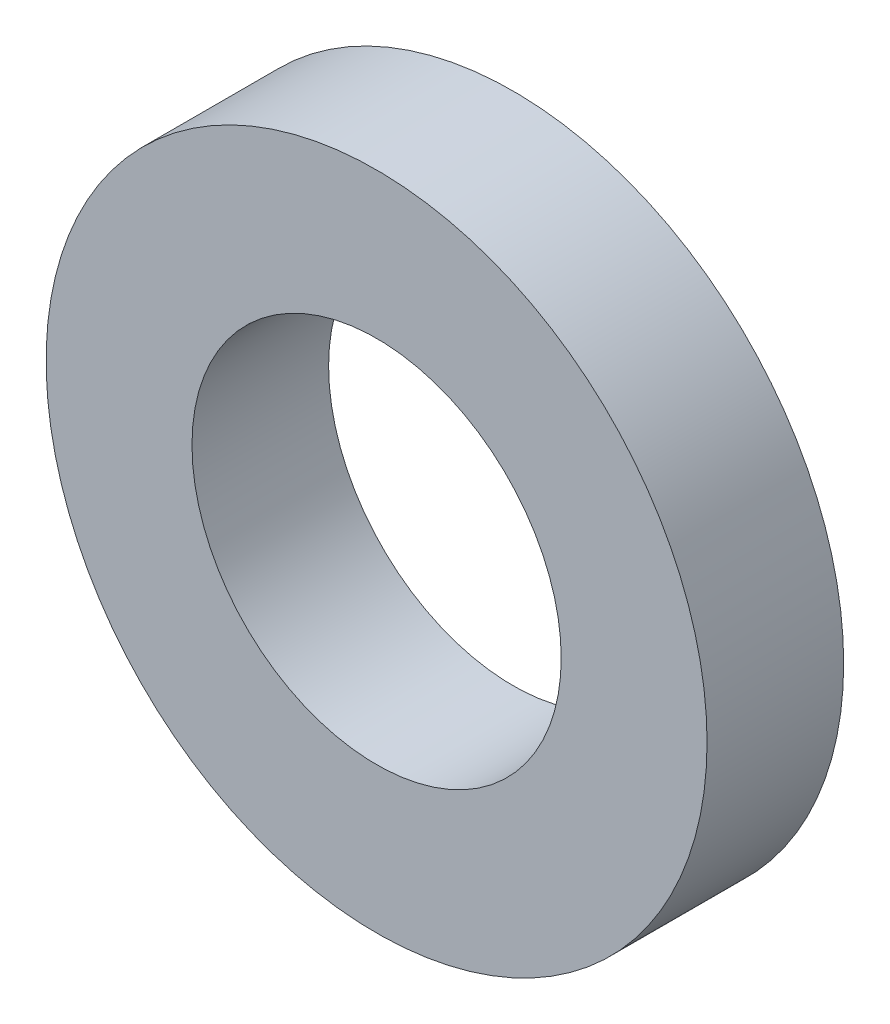
from build123d import *

# Parameters (mm, degrees)
SKETCH1_R           = 8.95
SKETCH1_R_2         = 5
BOSS_EXTRUDE1_DEPTH = 3.7


with BuildPart() as part:
    # Sketch1 → Boss-Extrude1 (new body)
    with BuildSketch(Plane.XY):
        Circle(SKETCH1_R)
        Circle(SKETCH1_R_2, mode=Mode.SUBTRACT)
    extrude(amount=BOSS_EXTRUDE1_DEPTH)


solid = part.part
